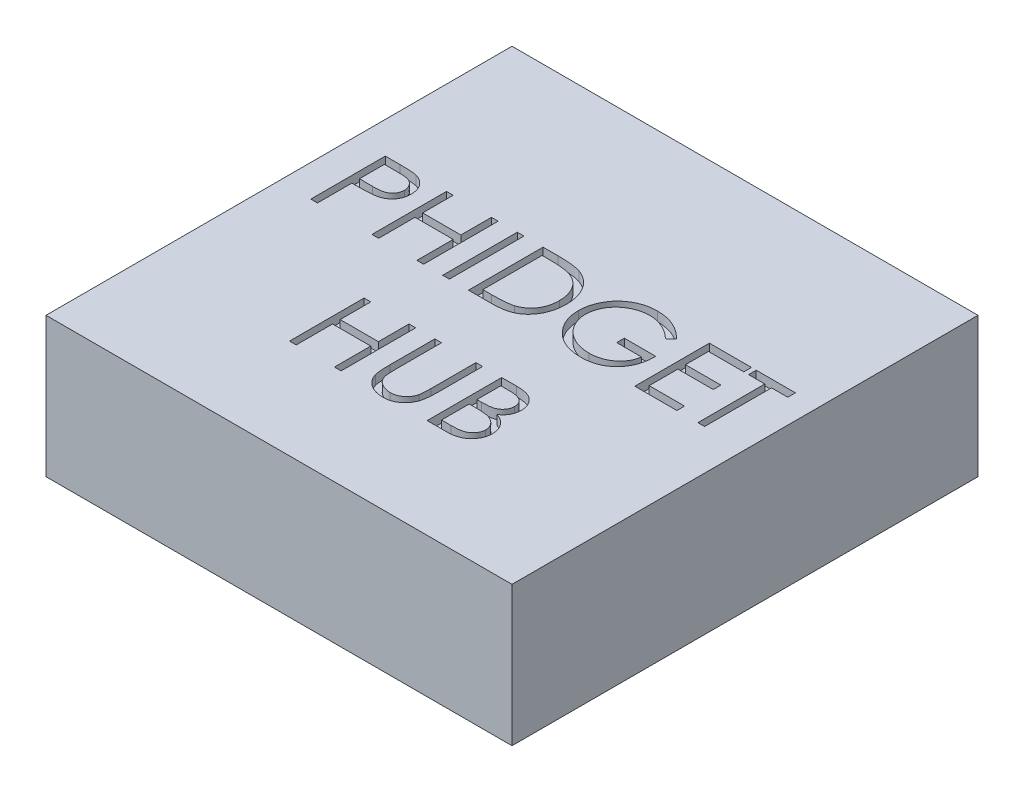
from build123d import *

# Parameters (mm, degrees)
SKETCH1_W           = 50
SKETCH1_H           = 50
BOSS_EXTRUDE1_DEPTH = 15
SKETCH2_W           = 0.717948718
SKETCH2_H           = 8
CUT_EXTRUDE1_DEPTH  = 1


with BuildPart() as part:
    # Sketch1 → Boss-Extrude1 (new body)
    with BuildSketch(Plane(origin=(0, 0, 0), x_dir=(1, 0, 0), z_dir=(0, 1, 0))):
        with Locations((25, 25)):
            Rectangle(SKETCH1_W, SKETCH1_H)
    extrude(amount=BOSS_EXTRUDE1_DEPTH)

    # Sketch2 → Cut-Extrude1 (cut)
    with BuildSketch(Plane(origin=(0, 15, 0), x_dir=(1, 0, 0), z_dir=(0, 1, 0))):
        with BuildLine():
            Line((3.41025641, 33), (4.979166667, 33))
            add(Edge.make_bspline(
                [(4.979166667, 33), (5.087077309, 32.99988138), (5.293838893, 32.999654099), (5.590330449, 32.992763251), (5.859609835, 32.983559384), (6.10109642, 32.970800771), (6.315533216, 32.95572285), (6.501949901, 32.934575331), (6.661811744, 32.912494656), (6.757597914, 32.890045727), (6.801282051, 32.879807692)],
                knots=[0, 0, 0, 0, 1.415646017, 2.712440637, 3.8905458, 4.950247383, 5.884950622, 6.709939814, 7.411656543, 8, 8, 8, 8], degree=3))
            add(Edge.make_bspline(
                [(6.801282051, 32.879807692), (6.856581557, 32.864671807), (6.965877505, 32.834756695), (7.123365604, 32.774839612), (7.273202965, 32.703794663), (7.41590367, 32.622825658), (7.549714145, 32.528458654), (7.67663081, 32.424518956), (7.795533622, 32.3086068), (7.905753947, 32.182022251), (8.006976341, 32.046890343), (8.094129902, 31.901193818), (8.167106421, 31.747385124), (8.229696755, 31.585571247), (8.274744651, 31.414393365), (8.308680422, 31.235040879), (8.330220142, 31.047533016), (8.332283141, 30.919396176), (8.333333333, 30.854166667)],
                knots=[0, 0, 0, 0, 0.999701418, 1.975846123, 2.934577507, 3.890451536, 4.834027766, 5.787354733, 6.749476667, 7.726910423, 8.712836071, 9.690891519, 10.682875813, 11.679750201, 12.712814741, 13.765529915, 14.8625177, 16, 16, 16, 16], degree=3))
            add(Edge.make_bspline(
                [(8.333333333, 30.854166667), (8.332370077, 30.788388891), (8.3304854, 30.659690231), (8.30786532, 30.471409572), (8.27739631, 30.291481823), (8.230545905, 30.120305936), (8.169184366, 29.958898461), (8.097202531, 29.804792788), (8.010383033, 29.660610681), (7.910623423, 29.525828698), (7.79964835, 29.400320327), (7.677927348, 29.284995082), (7.545951822, 29.180528023), (7.404141198, 29.086684952), (7.251112972, 29.005642027), (7.08918805, 28.933053901), (6.916958984, 28.872091477), (6.797776095, 28.840022765), (6.737179487, 28.823717949)],
                knots=[0, 0, 0, 0, 1.121902311, 2.195077645, 3.232258892, 4.234102512, 5.217864754, 6.176164875, 7.132989551, 8.084763148, 9.034132444, 9.988522005, 10.94243251, 11.903244335, 12.886203696, 13.894208494, 14.929344452, 16, 16, 16, 16], degree=3))
            add(Edge.make_bspline(
                [(6.737179487, 28.823717949), (6.687059867, 28.813059706), (6.577219804, 28.789701548), (6.396322153, 28.763625075), (6.185704128, 28.741367702), (5.945653203, 28.724679388), (5.676384849, 28.710392831), (5.377753403, 28.699037188), (5.049172656, 28.692797522), (4.819981241, 28.69247571), (4.700320513, 28.692307692)],
                knots=[0, 0, 0, 0, 0.601384939, 1.31797006, 2.144135048, 3.087295005, 4.142315834, 5.309527816, 6.595305764, 8, 8, 8, 8], degree=3))
            Line((4.700320513, 28.692307692), (4.128205128, 28.692307692))
            Line((4.128205128, 28.692307692), (4.128205128, 25))
            Line((4.128205128, 25), (3.41025641, 25))
            Line((3.41025641, 25), (3.41025641, 33))
        make_face()
        with BuildLine():
            Line((4.128205128, 32.179487179), (4.128205128, 29.512820513))
            Line((4.128205128, 29.512820513), (5.528846154, 29.495192308))
            add(Edge.make_bspline(
                [(5.528846154, 29.495192308), (5.597234556, 29.495156962), (5.729256956, 29.495088729), (5.919968323, 29.504197811), (6.096903837, 29.514713314), (6.259520009, 29.530109711), (6.407890145, 29.551872585), (6.54226164, 29.573842272), (6.661592572, 29.605625958), (6.80124789, 29.648421544), (6.95686697, 29.72141038), (7.126164224, 29.827352986), (7.26963985, 29.962394605), (7.393795957, 30.114229648), (7.492323678, 30.283141944), (7.56445166, 30.463870942), (7.606831448, 30.654563169), (7.612514177, 30.785050344), (7.615384615, 30.850961538)],
                knots=[0, 0, 0, 0, 1.160613943, 2.240541288, 3.23993089, 4.169200891, 5.011653406, 5.7853311, 6.478053781, 7.106038997, 8.262395093, 9.384106736, 10.481365981, 11.59014053, 12.70357646, 13.786202915, 14.881775077, 16, 16, 16, 16], degree=3))
            add(Edge.make_bspline(
                [(7.615384615, 30.850961538), (7.612498566, 30.915278141), (7.606761458, 31.043131586), (7.564119485, 31.23051161), (7.49246391, 31.409336077), (7.393134551, 31.576131701), (7.272583397, 31.727420395), (7.132470613, 31.8588424), (6.973126016, 31.964492006), (6.824901488, 32.032682364), (6.693241634, 32.07431728), (6.578882868, 32.103448344), (6.449761327, 32.126706872), (6.305834973, 32.145540021), (6.148219353, 32.161662219), (5.975560348, 32.172601595), (5.78851202, 32.179004924), (5.658659287, 32.179322536), (5.591346154, 32.179487179)],
                knots=[0, 0, 0, 0, 1.120700087, 2.227813068, 3.331159281, 4.466773991, 5.599788987, 6.693661531, 7.80175334, 8.91857717, 9.525282508, 10.207424825, 10.974604443, 11.810962634, 12.737642355, 13.736264703, 14.826523623, 16, 16, 16, 16], degree=3))
            Line((5.591346154, 32.179487179), (4.128205128, 32.179487179))
        make_face(mode=Mode.SUBTRACT)
        Polygon((9.974358974, 33), (10.692307692, 33), (10.692307692, 29.717948718), (14.794871795, 29.717948718), (14.794871795, 33), (15.512820513, 33), (15.512820513, 25), (14.794871795, 25), (14.794871795, 28.897435897), (10.692307692, 28.897435897), (10.692307692, 25), (9.974358974, 25), align=None)
        with Locations((17.923076923, 29)):
            Rectangle(SKETCH2_W, SKETCH2_H)
        with BuildLine():
            Line((20.333333333, 25), (20.333333333, 33))
            Line((20.333333333, 33), (21.948717949, 33))
            add(Edge.make_bspline(
                [(21.948717949, 33), (22.089218493, 32.998988411), (22.360664814, 32.997034028), (22.752921837, 32.984642276), (23.115856151, 32.962721212), (23.448274114, 32.930790866), (23.751088313, 32.891583932), (24.023450846, 32.842440151), (24.26677003, 32.784410047), (24.416414466, 32.734934732), (24.487179487, 32.711538462)],
                knots=[0, 0, 0, 0, 1.314313732, 2.53924729, 3.670748893, 4.714932338, 5.66265055, 6.526160246, 7.303039223, 8, 8, 8, 8], degree=3))
            add(Edge.make_bspline(
                [(24.487179487, 32.711538462), (24.579738891, 32.676268277), (24.762758759, 32.606527719), (25.023346468, 32.474970459), (25.268661583, 32.325911941), (25.500019629, 32.159155683), (25.712135804, 31.96998003), (25.91329671, 31.766420977), (26.095273222, 31.541076199), (26.261920756, 31.298619084), (26.412173692, 31.041905821), (26.542777481, 30.771425573), (26.651243751, 30.488551955), (26.741285412, 30.194071616), (26.812248744, 29.887337038), (26.860664588, 29.567991059), (26.892598279, 29.237295769), (26.895807539, 29.012896995), (26.897435897, 28.899038462)],
                knots=[0, 0, 0, 0, 0.984719456, 1.947108742, 2.898477687, 3.838006223, 4.779231079, 5.722358779, 6.681677486, 7.655904652, 8.64651281, 9.637519902, 10.640069247, 11.656948941, 12.698408672, 13.768548281, 14.867775369, 16, 16, 16, 16], degree=3))
            add(Edge.make_bspline(
                [(26.897435897, 28.899038462), (26.895998257, 28.800155631), (26.893165238, 28.605296685), (26.867726802, 28.318117495), (26.830752356, 28.039457903), (26.773508475, 27.770644874), (26.704017016, 27.509323233), (26.614956098, 27.258278103), (26.512932107, 27.015206539), (26.393960956, 26.783395166), (26.263352076, 26.563776029), (26.123188092, 26.35674625), (25.973618502, 26.165260029), (25.813217056, 25.988737487), (25.644056561, 25.827444737), (25.46502952, 25.680034416), (25.275673975, 25.549390862), (25.076838037, 25.430380329), (24.86272117, 25.326562373), (24.629267762, 25.238722351), (24.375482212, 25.165930087), (24.101987454, 25.105196611), (23.808310933, 25.057019919), (23.494164725, 25.024731022), (23.160031492, 25.002895748), (22.930593171, 25.000983992), (22.8125, 25)],
                knots=[0, 0, 0, 0, 1.105936401, 2.179363191, 3.223086493, 4.248585256, 5.251745608, 6.245858792, 7.225916811, 8.198733463, 9.158002045, 10.082870192, 10.993790845, 11.873723703, 12.748670949, 13.606408763, 14.465103618, 15.319838547, 16.196477973, 17.123216899, 18.106603292, 19.147568657, 20.255746949, 21.433717677, 22.679120308, 24, 24, 24, 24], degree=3))
            Line((22.8125, 25), (20.333333333, 25))
        make_face()
        with BuildLine():
            Line((21.051282051, 25.820512821), (21.969551282, 25.820512821))
            add(Edge.make_bspline(
                [(21.969551282, 25.820512821), (22.101501844, 25.821079898), (22.355291097, 25.822170596), (22.720223662, 25.831741346), (23.053662283, 25.84738006), (23.355654304, 25.869265952), (23.626029217, 25.898222787), (23.865352074, 25.930508279), (24.072838379, 25.970731023), (24.198391377, 26.007190359), (24.256410256, 26.024038462)],
                knots=[0, 0, 0, 0, 1.375205317, 2.645023457, 3.804390687, 4.853969522, 5.800190428, 6.637939096, 7.370582563, 8, 8, 8, 8], degree=3))
            add(Edge.make_bspline(
                [(24.256410256, 26.024038462), (24.329435084, 26.049756309), (24.473740543, 26.100577734), (24.681468737, 26.193280959), (24.875199034, 26.303091404), (25.058307663, 26.425153745), (25.228197161, 26.563773178), (25.386880856, 26.715935438), (25.534039259, 26.882414924), (25.668151963, 27.063005008), (25.788170943, 27.256581683), (25.892105182, 27.461241875), (25.983194397, 27.674743155), (26.054688323, 27.900364089), (26.110723944, 28.136087651), (26.150414659, 28.381930424), (26.17513403, 28.637846497), (26.178017339, 28.811908495), (26.179487179, 28.900641026)],
                knots=[0, 0, 0, 0, 0.998632004, 1.973411704, 2.929992603, 3.868527914, 4.809262121, 5.754881198, 6.702106254, 7.672490631, 8.653608572, 9.636854334, 10.631411391, 11.644891563, 12.686317036, 13.754757253, 14.855430412, 16, 16, 16, 16], degree=3))
            add(Edge.make_bspline(
                [(26.179487179, 28.900641026), (26.178313951, 28.994203266), (26.176009134, 29.178007116), (26.147039282, 29.447700134), (26.104704298, 29.707084478), (26.043484444, 29.956177496), (25.965471006, 30.195465158), (25.868111825, 30.423624039), (25.756873838, 30.643063739), (25.624523354, 30.848719432), (25.479573426, 31.043217967), (25.318709702, 31.221400631), (25.1444879, 31.383673318), (24.958808244, 31.532563175), (24.756437731, 31.662080149), (24.542143581, 31.77793542), (24.312782047, 31.876257457), (24.153210171, 31.928552001), (24.072115385, 31.955128205)],
                knots=[0, 0, 0, 0, 1.122418816, 2.205001699, 3.251619955, 4.274784885, 5.280384055, 6.268708349, 7.249350384, 8.229342522, 9.199999885, 10.157847722, 11.105861043, 12.055065948, 13.010012805, 13.98527497, 14.976112212, 16, 16, 16, 16], degree=3))
            add(Edge.make_bspline(
                [(24.072115385, 31.955128205), (24.00502705, 31.97368004), (23.862378844, 32.013126332), (23.629602926, 32.056155755), (23.367625442, 32.094108895), (23.075283268, 32.126241557), (22.752909647, 32.149298291), (22.400256646, 32.166604153), (22.017171835, 32.178276456), (21.751611758, 32.179073501), (21.613782051, 32.179487179)],
                knots=[0, 0, 0, 0, 0.674548936, 1.434276114, 2.292660221, 3.240891867, 4.284742987, 5.42552168, 6.663806718, 8, 8, 8, 8], degree=3))
            Line((21.613782051, 32.179487179), (21.051282051, 32.179487179))
            Line((21.051282051, 32.179487179), (21.051282051, 25.820512821))
        make_face(mode=Mode.SUBTRACT)
        with BuildLine():
            Line((36.025641026, 31.634615385), (35.41025641, 31.051282051))
            add(Edge.make_bspline(
                [(35.41025641, 31.051282051), (35.298898952, 31.15603831), (35.078839417, 31.363052853), (34.720073148, 31.631649414), (34.34575627, 31.861743357), (33.957841992, 32.048957612), (33.565936726, 32.19833535), (33.17524238, 32.304685385), (32.789766491, 32.372508327), (32.533384277, 32.380618886), (32.407051282, 32.384615385)],
                knots=[0, 0, 0, 0, 1.08915593, 2.152340314, 3.188132944, 4.216796309, 5.218260357, 6.173443236, 7.099959455, 8, 8, 8, 8], degree=3))
            add(Edge.make_bspline(
                [(32.407051282, 32.384615385), (32.329531968, 32.38367), (32.174694389, 32.381781682), (31.944701374, 32.357680618), (31.71712049, 32.323018072), (31.492381347, 32.272865209), (31.270046979, 32.209301644), (31.050890654, 32.129792014), (30.834503557, 32.037094313), (30.622923943, 31.929980087), (30.417802792, 31.812311867), (30.224072882, 31.681915202), (30.040499399, 31.542969397), (29.870532713, 31.39199573), (29.713195143, 31.230361752), (29.564741722, 31.061074195), (29.430393617, 30.879507981), (29.309042382, 30.689003693), (29.200787255, 30.49290726), (29.105224618, 30.293106141), (29.025002702, 30.090263045), (28.961529662, 29.884123439), (28.909162453, 29.676282091), (28.872322208, 29.465299873), (28.851552557, 29.250950877), (28.847959917, 29.107414287), (28.846153846, 29.03525641)],
                knots=[0, 0, 0, 0, 1.02818874, 2.053710826, 3.065248034, 4.081641283, 5.106893873, 6.131558223, 7.173050175, 8.228653731, 9.27666206, 10.308777013, 11.325269123, 12.329503258, 13.32196095, 14.316845687, 15.314881793, 16.315733098, 17.311955233, 18.285320748, 19.252783886, 20.203351036, 21.145449891, 22.095197417, 23.042428769, 24, 24, 24, 24], degree=3))
            add(Edge.make_bspline(
                [(28.846153846, 29.03525641), (28.847881202, 28.961494542), (28.851331197, 28.814172226), (28.873411928, 28.59430006), (28.914390763, 28.377693426), (28.969174098, 28.16364055), (29.037701676, 27.95177484), (29.123124913, 27.743014818), (29.224303429, 27.537368209), (29.341415548, 27.336687942), (29.469841155, 27.141206746), (29.613711055, 26.957070696), (29.766535246, 26.781827777), (29.933881302, 26.619368888), (30.110383113, 26.465348554), (30.30131403, 26.324010218), (30.502919654, 26.192631422), (30.715507567, 26.072867949), (30.936771069, 25.96587701), (31.163643648, 25.870736676), (31.396850083, 25.792383905), (31.635164803, 25.728525382), (31.878303709, 25.676181845), (32.127500973, 25.642507605), (32.380924306, 25.61807142), (32.551755465, 25.616284745), (32.637820513, 25.615384615)],
                knots=[0, 0, 0, 0, 0.93586088, 1.869166235, 2.799637598, 3.729985548, 4.670839027, 5.622275134, 6.589130586, 7.576015415, 8.568469353, 9.55398029, 10.53834874, 11.515998671, 12.510579167, 13.508179873, 14.527009472, 15.561807829, 16.601455013, 17.643573243, 18.680854198, 19.719860599, 20.772568776, 21.833555941, 22.908541556, 24, 24, 24, 24], degree=3))
            add(Edge.make_bspline(
                [(32.637820513, 25.615384615), (32.741542449, 25.61755279), (32.945217323, 25.621810353), (33.244614906, 25.654953871), (33.532164782, 25.706717971), (33.807058961, 25.782525735), (34.069616723, 25.879219849), (34.320800589, 25.995780732), (34.558632951, 26.136679153), (34.783828777, 26.295705135), (34.991273772, 26.472881895), (35.178368913, 26.664069221), (35.342130031, 26.868339088), (35.484997915, 27.08448838), (35.603189125, 27.31430622), (35.700201228, 27.556666363), (35.774563037, 27.811677819), (35.805088694, 27.987887262), (35.820512821, 28.076923077)],
                knots=[0, 0, 0, 0, 1.13008108, 2.219097802, 3.278683437, 4.311054135, 5.322181354, 6.324827112, 7.324222904, 8.330512327, 9.32562643, 10.293043162, 11.24128371, 12.174520618, 13.111833804, 14.052305215, 15.015860969, 16, 16, 16, 16], degree=3))
            Line((35.820512821, 28.076923077), (33.153846154, 28.076923077))
            Line((33.153846154, 28.076923077), (33.153846154, 28.897435897))
            Line((33.153846154, 28.897435897), (36.538461538, 28.897435897))
            add(Edge.make_bspline(
                [(36.538461538, 28.897435897), (36.534562456, 28.744504494), (36.526931249, 28.445190113), (36.473402299, 28.008686637), (36.386964556, 27.596408481), (36.268883843, 27.20792146), (36.11602606, 26.843776105), (35.930031709, 26.503602697), (35.707924004, 26.189598855), (35.457614423, 25.899201132), (35.176700234, 25.640162933), (34.87277196, 25.412492218), (34.545327461, 25.220714811), (34.194676472, 25.06469044), (33.82196691, 24.942921309), (33.426336328, 24.856586276), (33.00832124, 24.804860646), (32.721837407, 24.798251779), (32.575320513, 24.794871795)],
                knots=[0, 0, 0, 0, 1.140356446, 2.231883559, 3.274166699, 4.278491846, 5.25512956, 6.21435461, 7.1637429, 8.11826594, 9.068280886, 10.0076534, 10.945064095, 11.891975133, 12.864533718, 13.863980011, 14.907571808, 16, 16, 16, 16], degree=3))
            add(Edge.make_bspline(
                [(32.575320513, 24.794871795), (32.485011632, 24.796172643), (32.306893413, 24.798738336), (32.043828434, 24.816972273), (31.78801673, 24.845042162), (31.539495567, 24.887431015), (31.297350785, 24.939350225), (31.062791734, 25.005834153), (30.834924895, 25.082791181), (30.61339807, 25.170324148), (30.400221964, 25.271745078), (30.194447068, 25.384452825), (29.994935923, 25.507866221), (29.803047546, 25.644119583), (29.617782125, 25.792193778), (29.440334254, 25.952385593), (29.269710533, 26.124205295), (29.162829474, 26.24621446), (29.108974359, 26.307692308)],
                knots=[0, 0, 0, 0, 1.107784379, 2.184907829, 3.233506516, 4.263428166, 5.276301166, 6.270063455, 7.25232949, 8.225834625, 9.190232166, 10.146266622, 11.1027726, 12.066435141, 13.031522626, 14.010570082, 14.99756817, 16, 16, 16, 16], degree=3))
            add(Edge.make_bspline(
                [(29.108974359, 26.307692308), (29.030835086, 26.405225229), (28.875853571, 26.598672125), (28.676360642, 26.908614855), (28.506300293, 27.229533393), (28.368316699, 27.562321115), (28.260572502, 27.906666744), (28.183301067, 28.262130267), (28.138027263, 28.629169423), (28.131504892, 28.87754717), (28.128205128, 29.003205128)],
                knots=[0, 0, 0, 0, 1.023165419, 2.029347347, 3.013907458, 3.994755782, 4.975994455, 5.96558838, 6.970761222, 8, 8, 8, 8], degree=3))
            add(Edge.make_bspline(
                [(28.128205128, 29.003205128), (28.129421673, 29.09729942), (28.1318393, 29.284292123), (28.161154765, 29.561908826), (28.203215149, 29.834596122), (28.265036988, 30.102131108), (28.342971308, 30.36469246), (28.440236418, 30.622402092), (28.553481895, 30.875412084), (28.685105886, 31.121980925), (28.831584651, 31.358836726), (28.990556583, 31.585025991), (29.164279098, 31.796429568), (29.349915211, 31.995724764), (29.54967976, 32.180407843), (29.7617013, 32.352188667), (29.986143226, 32.511297663), (30.223711638, 32.655228714), (30.470860631, 32.78451699), (30.726997777, 32.897863759), (30.992044888, 32.991539909), (31.264016265, 33.071022834), (31.544970552, 33.129800298), (31.832868922, 33.172426002), (32.129212035, 33.201593087), (32.32952296, 33.203938814), (32.431089744, 33.205128205)],
                knots=[0, 0, 0, 0, 1.008945113, 2.00506715, 2.99143336, 3.967273523, 4.948097931, 5.927297278, 6.919902385, 7.919676788, 8.923139349, 9.905703106, 10.883022732, 11.856032218, 12.825136022, 13.798837087, 14.781400844, 15.773989409, 16.776158564, 17.77167057, 18.775803737, 19.789618931, 20.80898985, 21.851988756, 22.910860228, 24, 24, 24, 24], degree=3))
            add(Edge.make_bspline(
                [(32.431089744, 33.205128205), (32.513920015, 33.203803653), (32.678162709, 33.201177221), (32.922564383, 33.182972311), (33.163188416, 33.154117725), (33.400391593, 33.114742213), (33.633366145, 33.06111092), (33.862775757, 32.996931984), (34.088952983, 32.922207818), (34.311188981, 32.833090455), (34.530978046, 32.731939312), (34.749542253, 32.618080061), (34.966134815, 32.489565765), (35.181131344, 32.346014827), (35.395887591, 32.189892729), (35.607006773, 32.016734275), (35.819584932, 31.833367976), (35.956274793, 31.701522984), (36.025641026, 31.634615385)],
                knots=[0, 0, 0, 0, 0.985871117, 1.954866573, 2.915460327, 3.869826059, 4.81536089, 5.759505086, 6.70452669, 7.649098992, 8.607881297, 9.583363685, 10.581137262, 11.603961102, 12.659522466, 13.73993555, 14.853081303, 16, 16, 16, 16], degree=3))
        make_face()
        Polygon((38.179487179, 33), (42.692307692, 33), (42.692307692, 32.179487179), (38.897435897, 32.179487179), (38.897435897, 29.717948718), (42.692307692, 29.717948718), (42.692307692, 28.897435897), (38.897435897, 28.897435897), (38.897435897, 25.820512821), (42.692307692, 25.820512821), (42.692307692, 25), (38.179487179, 25), align=None)
        Polygon((43.205128205, 32.179487179), (43.205128205, 33), (47.41025641, 33), (47.41025641, 32.179487179), (45.666666667, 32.179487179), (45.666666667, 25), (44.948717949, 25), (44.948717949, 32.179487179), align=None)
        Polygon((15.461538462, 18.666666667), (16.179487179, 18.666666667), (16.179487179, 15.384615385), (20.282051282, 15.384615385), (20.282051282, 18.666666667), (21, 18.666666667), (21, 10.666666667), (20.282051282, 10.666666667), (20.282051282, 14.564102564), (16.179487179, 14.564102564), (16.179487179, 10.666666667), (15.461538462, 10.666666667), align=None)
        with BuildLine():
            Line((23.051282051, 18.666666667), (23.769230769, 18.666666667))
            Line((23.769230769, 18.666666667), (23.769230769, 13.873397436))
            add(Edge.make_bspline(
                [(23.769230769, 13.873397436), (23.769123926, 13.805555754), (23.768921172, 13.676814472), (23.77027549, 13.493572642), (23.774068332, 13.330664164), (23.776459554, 13.187461084), (23.781779173, 13.064620519), (23.786117566, 12.961476951), (23.791695981, 12.878518774), (23.79840025, 12.830105229), (23.801282051, 12.809294872)],
                knots=[0, 0, 0, 0, 1.528628734, 2.90083645, 4.128790002, 5.200304208, 6.127813768, 6.898992206, 7.526736466, 8, 8, 8, 8], degree=3))
            add(Edge.make_bspline(
                [(23.801282051, 12.809294872), (23.813116243, 12.734216556), (23.836117812, 12.588290318), (23.894738104, 12.380499959), (23.976606677, 12.193228054), (24.073619346, 12.020630818), (24.201465315, 11.86751228), (24.354616253, 11.726457074), (24.540165438, 11.603092949), (24.746475394, 11.490291093), (24.968841651, 11.399628048), (25.196067403, 11.331071787), (25.42473707, 11.289291444), (25.577825447, 11.284453641), (25.653846154, 11.282051282)],
                knots=[0, 0, 0, 0, 1.035780045, 2.013197591, 2.933192213, 3.817615948, 4.702609284, 5.640816605, 6.646850145, 7.73207398, 8.84249596, 9.914020372, 10.964143139, 12, 12, 12, 12], degree=3))
            add(Edge.make_bspline(
                [(25.653846154, 11.282051282), (25.719111846, 11.284505797), (25.849266273, 11.28940065), (26.042652401, 11.319712493), (26.230995506, 11.374342357), (26.415225632, 11.444833233), (26.587913596, 11.537970584), (26.749155749, 11.645561075), (26.893073313, 11.771757363), (27.02440588, 11.911415293), (27.138771447, 12.068991979), (27.237905485, 12.241056294), (27.31910761, 12.430197659), (27.359207095, 12.563122052), (27.379807692, 12.631410256)],
                knots=[0, 0, 0, 0, 0.994687771, 1.983630487, 2.973142513, 3.978332533, 4.983357753, 5.956394766, 6.925816176, 7.893390482, 8.871859704, 9.88551698, 10.913711441, 12, 12, 12, 12], degree=3))
            add(Edge.make_bspline(
                [(27.379807692, 12.631410256), (27.386665122, 12.659635569), (27.401946237, 12.722532941), (27.416225197, 12.828867319), (27.431097256, 12.954328723), (27.441416273, 13.09981858), (27.451476205, 13.264849375), (27.457494657, 13.450280821), (27.460276447, 13.655439588), (27.46110543, 13.798610244), (27.461538462, 13.873397436)],
                knots=[0, 0, 0, 0, 0.558680831, 1.244966039, 2.062412453, 2.990489873, 4.051219941, 5.244515665, 6.560634259, 8, 8, 8, 8], degree=3))
            Line((27.461538462, 13.873397436), (27.461538462, 18.666666667))
            Line((27.461538462, 18.666666667), (28.179487179, 18.666666667))
            Line((28.179487179, 18.666666667), (28.179487179, 13.834935897))
            add(Edge.make_bspline(
                [(28.179487179, 13.834935897), (28.178906333, 13.747853888), (28.177772775, 13.577908053), (28.167942886, 13.328876375), (28.152269744, 13.09264099), (28.130125543, 12.86917014), (28.100783821, 12.659263491), (28.068154746, 12.461081163), (28.026601527, 12.276045752), (27.978068039, 12.102714511), (27.922585643, 11.937719052), (27.850720161, 11.781127933), (27.769749876, 11.628180734), (27.673716384, 11.481190771), (27.565804652, 11.339507221), (27.443629382, 11.203989335), (27.311231299, 11.072471515), (27.166409449, 10.948327364), (27.011551106, 10.834478959), (26.847116917, 10.734369768), (26.674370014, 10.649744357), (26.49375944, 10.580085101), (26.305208119, 10.527708874), (26.108711297, 10.488679947), (25.903821712, 10.466503267), (25.764473927, 10.463207427), (25.693910256, 10.461538462)],
                knots=[0, 0, 0, 0, 1.316592851, 2.569410997, 3.76748051, 4.895814652, 5.963796859, 6.97159953, 7.931736103, 8.829262218, 9.692595152, 10.560224239, 11.431080259, 12.30701507, 13.211635791, 14.121146779, 15.063487852, 16.031507147, 17.00238618, 17.966455255, 18.938106653, 19.907068911, 20.888905087, 21.893141452, 22.933117798, 24, 24, 24, 24], degree=3))
            add(Edge.make_bspline(
                [(25.693910256, 10.461538462), (25.616952308, 10.463332211), (25.465961087, 10.46685154), (25.243474076, 10.487017826), (25.030184485, 10.525002727), (24.823839623, 10.573368313), (24.627248772, 10.640073998), (24.437778042, 10.718012569), (24.258672486, 10.813732022), (24.087026477, 10.920231206), (23.927427035, 11.04005895), (23.780918685, 11.170665062), (23.647259552, 11.309957353), (23.528702532, 11.459443903), (23.423283367, 11.617962091), (23.332471451, 11.785960353), (23.254498321, 11.963373647), (23.214254739, 12.086695248), (23.193910256, 12.149038462)],
                knots=[0, 0, 0, 0, 1.13879206, 2.234305948, 3.301075583, 4.341971843, 5.366689343, 6.369221514, 7.369726634, 8.367512178, 9.355451585, 10.318319045, 11.268648973, 12.207971039, 13.137398894, 14.081662264, 15.030215811, 16, 16, 16, 16], degree=3))
            add(Edge.make_bspline(
                [(23.193910256, 12.149038462), (23.182076752, 12.191627203), (23.156409617, 12.284003132), (23.128923223, 12.436886535), (23.10581675, 12.612920632), (23.08408976, 12.812117474), (23.071269285, 13.034631455), (23.060029425, 13.28036612), (23.051202868, 13.549618604), (23.051254919, 13.737171782), (23.051282051, 13.834935897)],
                knots=[0, 0, 0, 0, 0.625038921, 1.35572334, 2.194682327, 3.136881307, 4.189498639, 5.346923369, 6.617055217, 8, 8, 8, 8], degree=3))
            Line((23.051282051, 13.834935897), (23.051282051, 18.666666667))
        make_face()
        with BuildLine():
            Line((30.230769231, 18.666666667), (31.791666667, 18.666666667))
            add(Edge.make_bspline(
                [(31.791666667, 18.666666667), (31.868074617, 18.666264951), (32.01617224, 18.665486327), (32.231530965, 18.653410599), (32.433242532, 18.636945068), (32.62136544, 18.610819142), (32.79581276, 18.57929508), (32.957110216, 18.5411195), (33.104744896, 18.495344383), (33.281002579, 18.422552883), (33.48196409, 18.314385641), (33.699560416, 18.154548921), (33.885627249, 17.959046148), (34.046053117, 17.738514364), (34.173598533, 17.495918315), (34.265871212, 17.237040169), (34.324289213, 16.965219044), (34.330297063, 16.778606066), (34.333333333, 16.684294872)],
                knots=[0, 0, 0, 0, 1.001505555, 1.941167018, 2.826882275, 3.653841531, 4.429895133, 5.150066043, 5.825578002, 6.45369114, 7.647487171, 8.808567382, 9.977351308, 11.170798116, 12.373658725, 13.556498008, 14.765093433, 16, 16, 16, 16], degree=3))
            add(Edge.make_bspline(
                [(34.333333333, 16.684294872), (34.330834548, 16.595946173), (34.3259242, 16.422332648), (34.278969322, 16.168403256), (34.205459222, 15.926686184), (34.103275796, 15.698063589), (33.970471233, 15.487701045), (33.81308079, 15.293901579), (33.623190956, 15.124870592), (33.480920693, 15.030372529), (33.408653846, 14.982371795)],
                knots=[0, 0, 0, 0, 1.044552857, 2.05264487, 3.044412934, 4.028983338, 5.005914585, 5.980388656, 6.974128949, 8, 8, 8, 8], degree=3))
            add(Edge.make_bspline(
                [(33.408653846, 14.982371795), (33.499534824, 14.947480369), (33.673412646, 14.880724427), (33.91269496, 14.76270051), (34.118854606, 14.634329972), (34.293476654, 14.494142885), (34.442819865, 14.343037032), (34.573226589, 14.178796771), (34.684498301, 13.99927961), (34.779842126, 13.806357244), (34.854239283, 13.601999602), (34.909955636, 13.388123542), (34.941881234, 13.165495987), (34.946424414, 13.013986549), (34.948717949, 12.9375)],
                knots=[0, 0, 0, 0, 1.27268992, 2.434971085, 3.483601985, 4.442670788, 5.356604649, 6.2567628, 7.179492994, 8.113709626, 9.066344395, 10.018646069, 10.999752585, 12, 12, 12, 12], degree=3))
            add(Edge.make_bspline(
                [(34.948717949, 12.9375), (34.946485158, 12.859404292), (34.942092079, 12.705748799), (34.909680715, 12.480022778), (34.854802756, 12.264308614), (34.779211565, 12.057211053), (34.680554845, 11.859130746), (34.560490927, 11.669843286), (34.417333067, 11.49125053), (34.257189367, 11.321367963), (34.076018749, 11.168618735), (33.880554166, 11.032582834), (33.668334006, 10.92070612), (33.442843734, 10.826726642), (33.201553869, 10.75493876), (32.945547909, 10.704715734), (32.675046648, 10.67087565), (32.489424359, 10.668093467), (32.394230769, 10.666666667)],
                knots=[0, 0, 0, 0, 0.978564426, 1.925352924, 2.850884081, 3.763762016, 4.682927383, 5.618979971, 6.567305752, 7.547517671, 8.540179244, 9.531824382, 10.526200242, 11.540722885, 12.589160233, 13.674978461, 14.80764778, 16, 16, 16, 16], degree=3))
            Line((32.394230769, 10.666666667), (30.230769231, 10.666666667))
            Line((30.230769231, 10.666666667), (30.230769231, 18.666666667))
        make_face()
        with BuildLine():
            Line((30.948717949, 17.846153846), (30.948717949, 15.282051282))
            Line((30.948717949, 15.282051282), (31.431089744, 15.282051282))
            add(Edge.make_bspline(
                [(31.431089744, 15.282051282), (31.501601276, 15.282965392), (31.637843926, 15.284731638), (31.835146546, 15.289791106), (32.018289445, 15.303958062), (32.186956492, 15.318120947), (32.340882078, 15.341148576), (32.47972519, 15.368559142), (32.60566484, 15.39754864), (32.750898087, 15.446850324), (32.915636255, 15.519713582), (33.091254779, 15.632792064), (33.246076424, 15.7674763), (33.376812853, 15.922884213), (33.4838105, 16.094006923), (33.558127563, 16.278114078), (33.608521355, 16.470617237), (33.613073427, 16.602773244), (33.615384615, 16.669871795)],
                knots=[0, 0, 0, 0, 1.156816544, 2.235205308, 3.236616184, 4.169592532, 5.011045266, 5.787822928, 6.49130361, 7.128639758, 8.301311294, 9.436451833, 10.541879658, 11.654887649, 12.756523258, 13.837046038, 14.901820046, 16, 16, 16, 16], degree=3))
            add(Edge.make_bspline(
                [(33.615384615, 16.669871795), (33.614181918, 16.714273558), (33.611822695, 16.801372466), (33.592500861, 16.928342418), (33.559660691, 17.04775671), (33.517479449, 17.161251819), (33.458533875, 17.265278905), (33.389131673, 17.363434781), (33.305278666, 17.452376766), (33.20983338, 17.535507048), (33.100099385, 17.609208826), (32.976142147, 17.673759142), (32.836284599, 17.72573806), (32.682883788, 17.771260694), (32.513578445, 17.803233937), (32.330322323, 17.829870252), (32.131614394, 17.843430805), (31.994139874, 17.84522592), (31.923076923, 17.846153846)],
                knots=[0, 0, 0, 0, 0.91205012, 1.789085906, 2.630437955, 3.453916878, 4.269457761, 5.079663411, 5.91843418, 6.774407191, 7.675494373, 8.627863946, 9.638891023, 10.736472738, 11.911756761, 13.175263542, 14.539845004, 16, 16, 16, 16], degree=3))
            Line((31.923076923, 17.846153846), (30.948717949, 17.846153846))
        make_face(mode=Mode.SUBTRACT)
        with BuildLine():
            Line((30.948717949, 14.461538462), (30.948717949, 11.487179487))
            Line((30.948717949, 11.487179487), (31.971153846, 11.487179487))
            add(Edge.make_bspline(
                [(31.971153846, 11.487179487), (32.044339963, 11.488056624), (32.185396554, 11.48974719), (32.389056508, 11.495266172), (32.577817888, 11.507819945), (32.750819341, 11.527581887), (32.909928947, 11.549018342), (33.053237983, 11.577844127), (33.181908139, 11.610870323), (33.331106557, 11.661919859), (33.499114576, 11.741226078), (33.680167962, 11.860801453), (33.841142175, 12.003254728), (33.97783991, 12.168125389), (34.089869598, 12.347396993), (34.171367781, 12.537443507), (34.221632597, 12.735124713), (34.227717555, 12.86990577), (34.230769231, 12.9375)],
                knots=[0, 0, 0, 0, 1.160039823, 2.235823828, 3.228722157, 4.157150951, 4.99529583, 5.772374946, 6.472645482, 7.099169577, 8.269452708, 9.405989375, 10.527446681, 11.663510218, 12.788923519, 13.866172445, 14.929861265, 16, 16, 16, 16], degree=3))
            add(Edge.make_bspline(
                [(34.230769231, 12.9375), (34.230138135, 12.979770493), (34.228886124, 13.063629651), (34.210004718, 13.186865809), (34.182544444, 13.306239234), (34.147044024, 13.422074069), (34.095342385, 13.532276072), (34.034984568, 13.63902478), (33.96421565, 13.742461304), (33.85394327, 13.873232169), (33.693550163, 14.023899627), (33.465648962, 14.171413918), (33.206512281, 14.290380334), (33.018563726, 14.340893423), (32.921474359, 14.366987179)],
                knots=[0, 0, 0, 0, 0.723448775, 1.435228256, 2.130040452, 2.821711965, 3.505591119, 4.210454504, 4.921174351, 5.648778258, 7.137944449, 8.670945889, 10.280296675, 12, 12, 12, 12], degree=3))
            add(Edge.make_bspline(
                [(32.921474359, 14.366987179), (32.882550711, 14.374884514), (32.798156215, 14.392007565), (32.660538888, 14.410082316), (32.50342833, 14.42618531), (32.326461754, 14.438096527), (32.12941526, 14.450408627), (31.911868017, 14.455196789), (31.674708441, 14.460909384), (31.510154447, 14.461323405), (31.424679487, 14.461538462)],
                knots=[0, 0, 0, 0, 0.634451884, 1.375622551, 2.216452059, 3.157844607, 4.20941857, 5.370758133, 6.634282058, 8, 8, 8, 8], degree=3))
            Line((31.424679487, 14.461538462), (30.948717949, 14.461538462))
        make_face(mode=Mode.SUBTRACT)
    extrude(amount=-CUT_EXTRUDE1_DEPTH, mode=Mode.SUBTRACT)


solid = part.part
